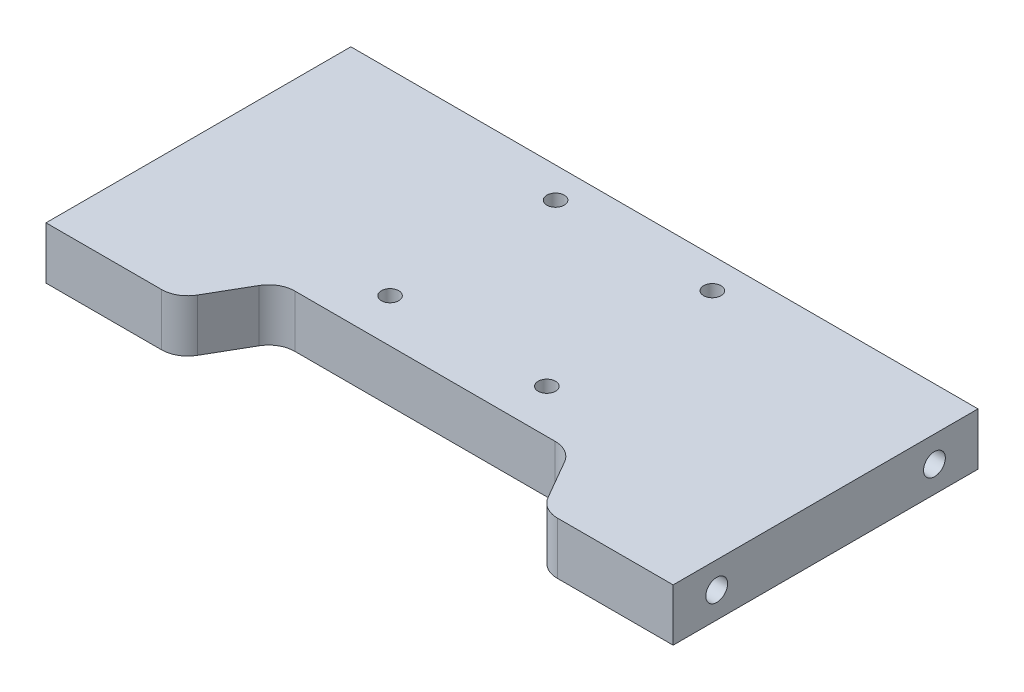
from build123d import *

# Parameters (mm, degrees)
SKETCH1_W                   = 72
SKETCH1_H                   = 35
BOSS_EXTRUDE1_DEPTH         = 6
CUT_EXTRUDE3_REACH          = 8
CUT_EXTRUDE4_REACH          = 8
SKETCH5_R                   = 1
FILLET1_R                   = 3
TAP_DRILL_FOR_M3_TAP1_D     = 2.5
TAP_DRILL_FOR_M3_TAP1_DEPTH = 10
TAP_DRILL_FOR_M3_TAP1_TIP   = 0.751075774
TAP_DRILL_FOR_M3_TAP2_D     = 2.5
TAP_DRILL_FOR_M3_TAP2_DEPTH = 10
TAP_DRILL_FOR_M3_TAP2_TIP   = 0.751075774


with BuildPart() as part:
    # Sketch1 → Boss-Extrude1 (new body)
    with BuildSketch(Plane(origin=(0, 0, 0), x_dir=(1, 0, 0), z_dir=(0, 1, 0))):
        with Locations((36, 17.5)):
            Rectangle(SKETCH1_W, SKETCH1_H)
    extrude(amount=BOSS_EXTRUDE1_DEPTH)

    # Sketch4 → Cut-Extrude3 (cut, up to next)
    with BuildSketch(Plane(origin=(0, 6, 0), x_dir=(1, 0, 0), z_dir=(0, 1, 0)), mode=Mode.PRIVATE) as cut_extrude3_sk1:
        Polygon((15, 0), (57, 0), (52.669872981, 7.5), (19.330127019, 7.5), align=None)
    cut_extrude3_tool1 = extrude(cut_extrude3_sk1.sketch, amount=-CUT_EXTRUDE3_REACH, mode=Mode.PRIVATE) & part.part
    add(cut_extrude3_tool1.solids().sort_by_distance((36, 6, -3.606313))[0], mode=Mode.SUBTRACT)

    # Sketch5 → Cut-Extrude4 (cut, up to next)
    with BuildSketch(Plane(origin=(0, 6, 0), x_dir=(1, 0, 0), z_dir=(0, 1, 0)), mode=Mode.PRIVATE) as cut_extrude4_sk1:
        with Locations((27, 12.5)):
            Circle(SKETCH5_R)
    cut_extrude4_tool1 = extrude(cut_extrude4_sk1.sketch, amount=-CUT_EXTRUDE4_REACH, mode=Mode.PRIVATE) & part.part
    add(cut_extrude4_tool1.solids().sort_by_distance((27, 6, -12.5))[0], mode=Mode.SUBTRACT)
    # Sketch5 → Cut-Extrude4 (cut, up to next)
    with BuildSketch(Plane(origin=(0, 6, 0), x_dir=(1, 0, 0), z_dir=(0, 1, 0)), mode=Mode.PRIVATE) as cut_extrude4_sk2:
        with Locations((45, 12.5)):
            Circle(SKETCH5_R)
    cut_extrude4_tool2 = extrude(cut_extrude4_sk2.sketch, amount=-CUT_EXTRUDE4_REACH, mode=Mode.PRIVATE) & part.part
    add(cut_extrude4_tool2.solids().sort_by_distance((45, 6, -12.5))[0], mode=Mode.SUBTRACT)
    # Sketch5 → Cut-Extrude4 (cut, up to next)
    with BuildSketch(Plane(origin=(0, 6, 0), x_dir=(1, 0, 0), z_dir=(0, 1, 0)), mode=Mode.PRIVATE) as cut_extrude4_sk3:
        with Locations((45, 31.5)):
            Circle(SKETCH5_R)
    cut_extrude4_tool3 = extrude(cut_extrude4_sk3.sketch, amount=-CUT_EXTRUDE4_REACH, mode=Mode.PRIVATE) & part.part
    add(cut_extrude4_tool3.solids().sort_by_distance((45, 6, -31.5))[0], mode=Mode.SUBTRACT)
    # Sketch5 → Cut-Extrude4 (cut, up to next)
    with BuildSketch(Plane(origin=(0, 6, 0), x_dir=(1, 0, 0), z_dir=(0, 1, 0)), mode=Mode.PRIVATE) as cut_extrude4_sk4:
        with Locations((27, 31.5)):
            Circle(SKETCH5_R)
    cut_extrude4_tool4 = extrude(cut_extrude4_sk4.sketch, amount=-CUT_EXTRUDE4_REACH, mode=Mode.PRIVATE) & part.part
    add(cut_extrude4_tool4.solids().sort_by_distance((27, 6, -31.5))[0], mode=Mode.SUBTRACT)

    # Fillet1
    fillet1_edges = [part.edges().sort_by_distance(p)[0] for p in [
        (15, 3, 0),
        (19.330127019, 3, -7.5),
        (52.669872981, 3, -7.5),
        (57, 3, 0),
    ]]
    fillet(fillet1_edges, radius=FILLET1_R)

    # Tap Drill for M3 Tap1
    with Locations(Plane.ZY):
        with Locations((-30, 3), (-5, 3)):
            Hole(TAP_DRILL_FOR_M3_TAP1_D / 2, depth=TAP_DRILL_FOR_M3_TAP1_DEPTH)
            with Locations((0, 0, -(TAP_DRILL_FOR_M3_TAP1_DEPTH + TAP_DRILL_FOR_M3_TAP1_TIP / 2))):  # 118° drill point
                Cone(0, TAP_DRILL_FOR_M3_TAP1_D / 2, TAP_DRILL_FOR_M3_TAP1_TIP, mode=Mode.SUBTRACT)

    # Tap Drill for M3 Tap2
    with Locations(Plane(origin=(72, 0, 0), x_dir=(0, 0, -1), z_dir=(1, 0, 0))):
        with Locations((5, 3), (30, 3)):
            Hole(TAP_DRILL_FOR_M3_TAP2_D / 2, depth=TAP_DRILL_FOR_M3_TAP2_DEPTH)
            with Locations((0, 0, -(TAP_DRILL_FOR_M3_TAP2_DEPTH + TAP_DRILL_FOR_M3_TAP2_TIP / 2))):  # 118° drill point
                Cone(0, TAP_DRILL_FOR_M3_TAP2_D / 2, TAP_DRILL_FOR_M3_TAP2_TIP, mode=Mode.SUBTRACT)


solid = part.part
